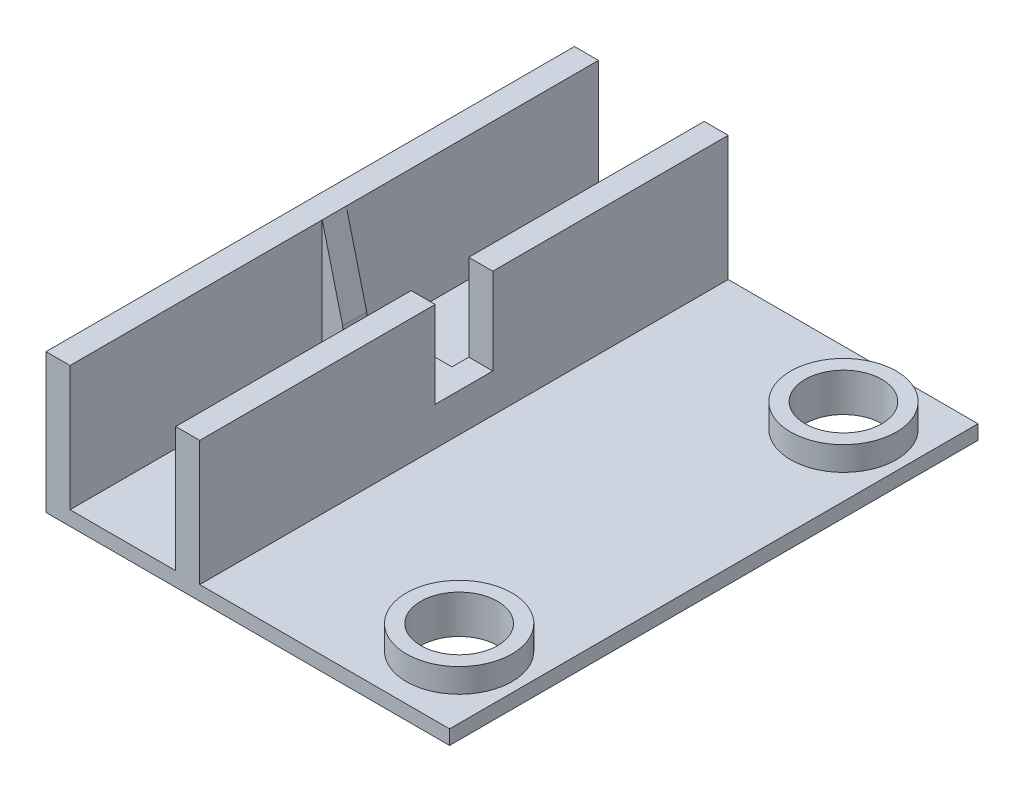
from build123d import *

# Parameters (mm, degrees)
SKETCH1_W                       = 42
SKETCH1_H                       = 55
BOSS_EXTRUDE1_DEPTH             = 1.5
BOSS_EXTRUDE2_REACH             = 29.5
SKETCH2_W                       = 16
SKETCH2_H                       = 13
BOSS_EXTRUDE2_DIRECTION_2_REACH = 29.5
SKETCH3_W                       = 11
SKETCH3_H                       = 13
CUT_EXTRUDE2_DEPTH              = 56
SKETCH6_W                       = 16
SKETCH6_H                       = 13.028292271
BOSS_EXTRUDE3_DEPTH             = 1.25
CUT_EXTRUDE5_DEPTH              = 2.5
SKETCH8_W                       = 6
SKETCH8_H                       = 9
CUT_EXTRUDE6_DEPTH              = 6.5
SKETCH9_R                       = 5.5
SKETCH9_R_2                     = 4
BOSS_EXTRUDE4_DEPTH             = 2.5
SKETCH11_R                      = 4
CUT_EXTRUDE7_DEPTH              = 2.5


with BuildPart() as part:
    # Sketch1 → Boss-Extrude1 (new body)
    with BuildSketch(Plane(origin=(0, 0, 0), x_dir=(1, 0, 0), z_dir=(0, 1, 0))):
        Rectangle(SKETCH1_W, SKETCH1_H)
    extrude(amount=BOSS_EXTRUDE1_DEPTH)

    # Boss-Extrude2: up to this face of the body (flat: up to its plane)
    boss_extrude2_end = Plane(part.part.faces().sort_by_distance((0, 0.75, 27.5))[0])
    # Sketch2 → Boss-Extrude2 (add, up to the picked face)
    with BuildSketch(Plane.XY, mode=Mode.PRIVATE) as boss_extrude2_sk1:
        with Locations((-13, 8)):
            Rectangle(SKETCH2_W, SKETCH2_H)
    boss_extrude2_tool1 = split(extrude(boss_extrude2_sk1.sketch, amount=BOSS_EXTRUDE2_REACH, mode=Mode.PRIVATE), bisect_by=boss_extrude2_end, keep=Keep.BOTH, mode=Mode.PRIVATE)
    add(boss_extrude2_tool1.solids().sort_by_distance((-13, 8, 0))[0])

    # Boss-Extrude2 direction 2: up to this face of the body (flat: up to its plane)
    boss_extrude2_direction_2_end = Plane(part.part.faces().sort_by_distance((0, 0.75, -27.5))[0])
    # Sketch2 → Boss-Extrude2 direction 2 (add, up to the picked face)
    with BuildSketch(Plane.XY, mode=Mode.PRIVATE) as boss_extrude2_direction_2_sk1:
        with Locations((-13, 8)):
            Rectangle(SKETCH2_W, SKETCH2_H)
    boss_extrude2_direction_2_tool1 = split(extrude(boss_extrude2_direction_2_sk1.sketch, amount=-BOSS_EXTRUDE2_DIRECTION_2_REACH, mode=Mode.PRIVATE), bisect_by=boss_extrude2_direction_2_end, keep=Keep.BOTH, mode=Mode.PRIVATE)
    add(boss_extrude2_direction_2_tool1.solids().sort_by_distance((-13, 8, 0))[0])

    # Sketch3 → Cut-Extrude2 (cut, through all)
    with BuildSketch(Plane.XY.offset(27.5)):
        with Locations((-13, 8)):
            Rectangle(SKETCH3_W, SKETCH3_H)
    extrude(amount=-CUT_EXTRUDE2_DEPTH, mode=Mode.SUBTRACT)

    # Sketch6 → Boss-Extrude3 (add, symmetric)
    with BuildSketch(Plane.XY):
        with Locations((-13, 7.985853865)):
            Rectangle(SKETCH6_W, SKETCH6_H)
    extrude(amount=BOSS_EXTRUDE3_DEPTH, both=True)

    # Sketch7 → Cut-Extrude5 (cut)
    with BuildSketch(Plane.XY.offset(1.25)):
        with BuildLine():
            Line((-7.5, 14.5), (-18.5, 14.5))
            Line((-18.5, 14.5), (-16.373292693, 6.010430414))
            ThreePointArc((-16.373292693, 6.010430414), (-13, 2.637137721), (-9.626707307, 6.010430414))
            Line((-9.626707307, 6.010430414), (-7.5, 14.5))
        make_face()
    extrude(amount=-CUT_EXTRUDE5_DEPTH, mode=Mode.SUBTRACT)

    # Sketch8 → Cut-Extrude6 (cut)
    with BuildSketch(Plane(origin=(-5, 0, 0), x_dir=(0, 0, -1), z_dir=(1, 0, 0))):
        with Locations((0, 10)):
            Rectangle(SKETCH8_W, SKETCH8_H)
    extrude(amount=-CUT_EXTRUDE6_DEPTH, mode=Mode.SUBTRACT)

    # Sketch9 → Boss-Extrude4 (add)
    with BuildSketch(Plane(origin=(0, 1.5, 0), x_dir=(1, 0, 0), z_dir=(0, 1, 0))):
        with Locations((14.5, 20)):
            Circle(SKETCH9_R)
        with Locations((14.5, 20)):
            Circle(SKETCH9_R_2, mode=Mode.SUBTRACT)
    boss_extrude4 = extrude(amount=BOSS_EXTRUDE4_DEPTH)

    # Sketch11 → Cut-Extrude7 (cut)
    with BuildSketch(Plane(origin=(0, 1.5, 0), x_dir=(1, 0, 0), z_dir=(0, 1, 0))):
        with Locations((14.5, 20)):
            Circle(SKETCH11_R)
    cut_extrude7 = extrude(amount=-CUT_EXTRUDE7_DEPTH, mode=Mode.SUBTRACT)

    # Mirror1: Boss-Extrude4, Cut-Extrude7 across plane
    add(boss_extrude4.mirror(Plane.XY))
    add(cut_extrude7.mirror(Plane.XY), mode=Mode.SUBTRACT)


solid = part.part
